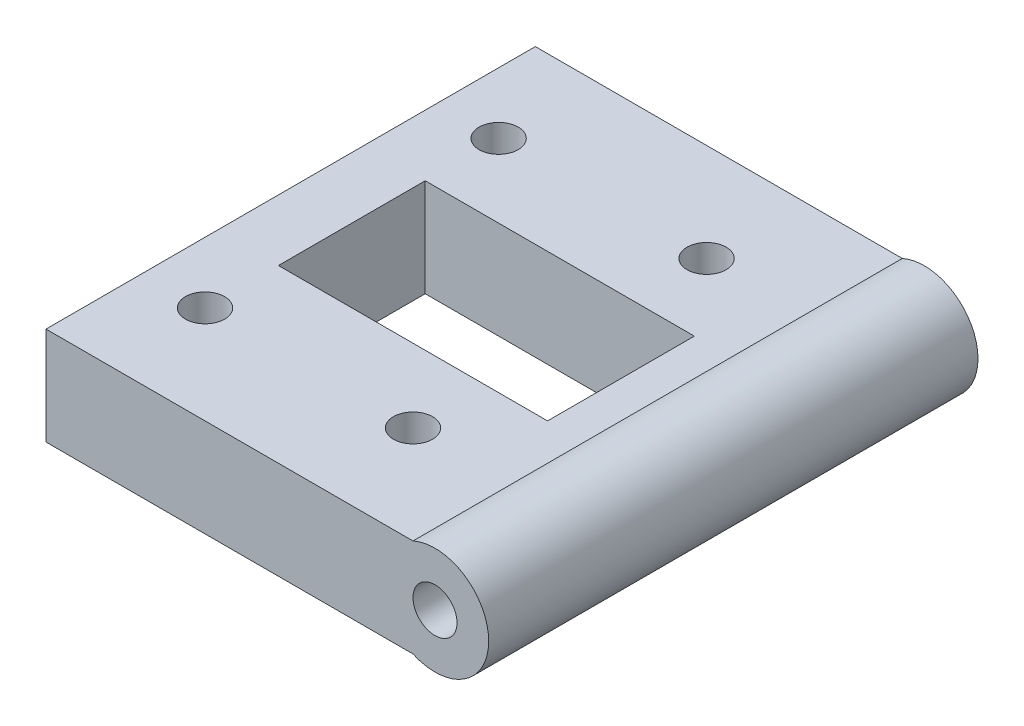
from build123d import *

# Parameters (mm, degrees)
SKETCH_1_W          = 30
SKETCH_1_H          = 40
EXTRUDE_1_DEPTH     = 8
SKETCH_2_R          = 4.38634244
SKETCH_2_R_2        = 1.8
EXTRUDE_2_DEPTH     = 40
SKETCH_3_R          = 1.6
CUT_EXTRUDE_1_DEPTH = 9.38634244
SKETCH_4_W          = 22
SKETCH_4_H          = 12
CUT_EXTRUDE_2_DEPTH = 9.38634244


with BuildPart() as part:
    # 草图1 → 凸台-拉伸1 (new body)
    with BuildSketch(Plane(origin=(0, 0, 0), x_dir=(1, 0, 0), z_dir=(0, 1, 0))):
        with Locations((36.36947716, -2.04637122)):
            Rectangle(SKETCH_1_W, SKETCH_1_H)
    extrude(amount=EXTRUDE_1_DEPTH)

    # 草图2 → 凸台-拉伸2 (add)
    with BuildSketch(Plane.XY.offset(22.04637122)):
        with Locations((53.16947716, 4)):
            Circle(SKETCH_2_R)
        with Locations((53.16947716, 4)):
            Circle(SKETCH_2_R_2, mode=Mode.SUBTRACT)
    extrude(amount=-EXTRUDE_2_DEPTH)

    # 草图3 → 切除-拉伸1 (cut, through all)
    with BuildSketch(Plane(origin=(0, 8, 0), x_dir=(1, 0, 0), z_dir=(0, 1, 0))):
        with Locations((26.36947716, 9.95362878)):
            Circle(SKETCH_3_R)
        with Locations((43.36947716, 9.95362878)):
            Circle(SKETCH_3_R)
        with Locations((43.36947716, -14.04637122)):
            Circle(SKETCH_3_R)
        with Locations((26.36947716, -14.04637122)):
            Circle(SKETCH_3_R)
    extrude(amount=-CUT_EXTRUDE_1_DEPTH, mode=Mode.SUBTRACT)

    # 草图4 → 切除-拉伸2 (cut, through all)
    with BuildSketch(Plane(origin=(0, 8, 0), x_dir=(1, 0, 0), z_dir=(0, 1, 0))):
        with Locations((37.36947716, -2.04637122)):
            Rectangle(SKETCH_4_W, SKETCH_4_H)
    extrude(amount=-CUT_EXTRUDE_2_DEPTH, mode=Mode.SUBTRACT)


solid = part.part
